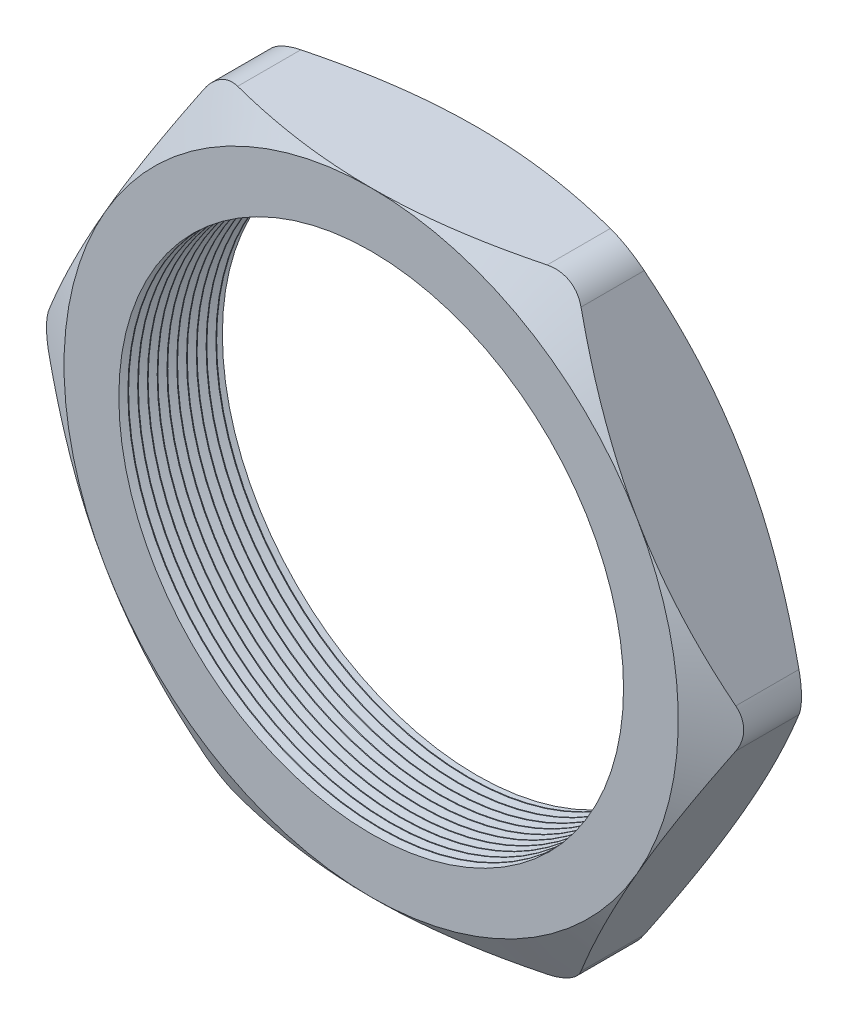
from build123d import *

# Parameters (mm, degrees)
SKETCH1_R          = 16.383
EXTRUDE1_DEPTH     = 6.858
SKETCH2_OUTSIDE_W  = 87.528
SKETCH2_OUTSIDE_H  = 81.358
SKETCH2_OUTSIDE_R  = 19.939
CUT_EXTRUDE1_DEPTH = 7.858
CUT_EXTRUDE1_DRAFT = -60
SKETCH3_OUTSIDE_W  = 87.528
SKETCH3_OUTSIDE_H  = 81.358
SKETCH3_OUTSIDE_R  = 19.939
CUT_EXTRUDE2_DEPTH = 7.858
CUT_EXTRUDE2_DRAFT = -60
FILLET1_R          = 2.54
LPATTERN1_COUNT    = 11
LPATTERN1_PITCH    = 0.635


with BuildPart() as part:
    # Sketch1 → Extrude1 (new body)
    with BuildSketch(Plane.XY):
        Polygon((-23.023574035, 0), (-11.511787017, -19.939), (11.511787017, -19.939), (23.023574035, 0), (11.511787017, 19.939), (-11.511787017, 19.939), align=None)
        Circle(SKETCH1_R, mode=Mode.SUBTRACT)
    extrude(amount=EXTRUDE1_DEPTH)


with BuildPart() as cut_extrude1_tool:
    # Sketch2 outside → Cut-Extrude1 (with draft: the straight prism first)
    with BuildSketch(Plane.XY.offset(6.858)):
        Rectangle(SKETCH2_OUTSIDE_W, SKETCH2_OUTSIDE_H)
        Circle(SKETCH2_OUTSIDE_R, mode=Mode.SUBTRACT)
    extrude(amount=-CUT_EXTRUDE1_DEPTH)
    # Cut-Extrude1: the draft: its side faces are tilted about the plane it starts from
    cut_extrude1_sides = [cut_extrude1_tool.faces().sort_by_distance(p)[0] for p in [
        (0, -40.679, 2.929),
        (43.764, 0, 2.929),
        (0, 40.679, 2.929),
        (-43.764, 0, 2.929),
        (-19.939, 0, 2.929),
    ]]
    draft(cut_extrude1_sides, Plane.XY.offset(6.858), CUT_EXTRUDE1_DRAFT)


with BuildPart() as part_1:
    add(part.part)

    # Cut-Extrude1: cut by cut_extrude1_tool
    add(cut_extrude1_tool.part, mode=Mode.SUBTRACT)


with BuildPart() as cut_extrude2_tool:
    # Sketch3 outside → Cut-Extrude2 (with draft: the straight prism first)
    with BuildSketch(Plane(origin=(0, 0, 0), x_dir=(-1, 0, 0), z_dir=(0, 0, -1))):
        Rectangle(SKETCH3_OUTSIDE_W, SKETCH3_OUTSIDE_H)
        Circle(SKETCH3_OUTSIDE_R, mode=Mode.SUBTRACT)
    extrude(amount=-CUT_EXTRUDE2_DEPTH)
    # Cut-Extrude2: the draft: its side faces are tilted about the plane it starts from
    cut_extrude2_sides = [cut_extrude2_tool.faces().sort_by_distance(p)[0] for p in [
        (0, -40.679, 3.929),
        (-43.764, 0, 3.929),
        (0, 40.679, 3.929),
        (43.764, 0, 3.929),
        (19.939, 0, 3.929),
    ]]
    draft(cut_extrude2_sides, Plane(origin=(0, 0, 0), x_dir=(-1, 0, 0), z_dir=(0, 0, -1)), CUT_EXTRUDE2_DRAFT)


with BuildPart() as part_2:
    add(part_1.part)

    # Cut-Extrude2: cut by cut_extrude2_tool
    add(cut_extrude2_tool.part, mode=Mode.SUBTRACT)

    # Fillet1
    fillet1_edges = [part_2.edges().sort_by_distance(p)[0] for p in [
        (23.023574035, 0, 3.429),
        (11.511787017, -19.939, 3.429),
        (-11.511787017, -19.939, 3.429),
        (-23.023574035, 0, 3.429),
        (-11.511787017, 19.939, 3.429),
        (11.511787017, 19.939, 3.429),
    ]]
    fillet(fillet1_edges, radius=FILLET1_R)

    # Sketch4 → Cut-Revolve1 (revolve, cut)
    with BuildSketch(Plane(origin=(0, 0, 0), x_dir=(1, 0, 0), z_dir=(0, 1, 0)), mode=Mode.PRIVATE) as cut_revolve1_sk:
        Polygon((-16.383, -6.858), (-16.383, -6.271412127), (-16.891, -6.564706063), align=None)
    cut_revolve1 = revolve(cut_revolve1_sk.sketch.rotate(Axis((0, 0, 0), (0, 0, 1)), 180), axis=Axis((0, 0, 0), (0, 0, 1)), mode=Mode.SUBTRACT)  # turned: the seam where the file's is

    # LPattern1: Cut-Revolve1 ×11
    with Locations(*[(0, 0, -i * LPATTERN1_PITCH) for i in range(1, LPATTERN1_COUNT)]):
        add(cut_revolve1, mode=Mode.SUBTRACT)


solid = part_2.part
